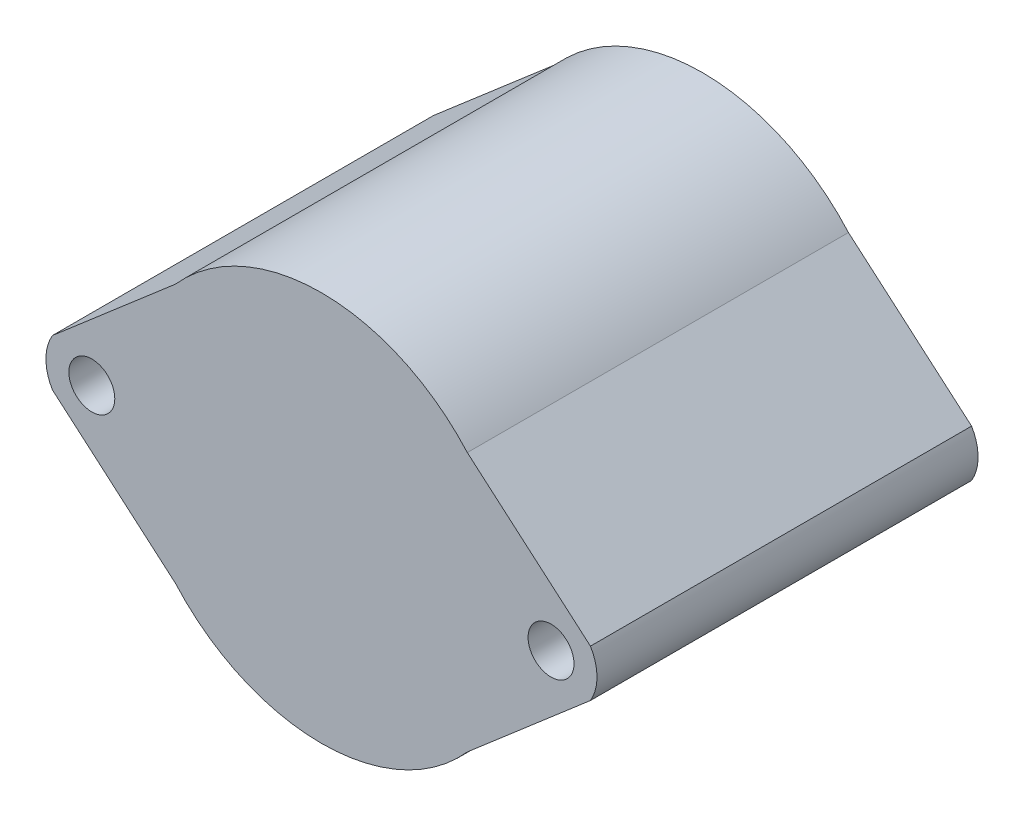
from build123d import *

# Parameters (mm, degrees)
SKETCH2_R           = 2
BOSS_EXTRUDE2_DEPTH = 33.2


with BuildPart() as part:
    # Sketch2 → Boss-Extrude2 (new body)
    with BuildSketch(Plane.XY):
        with BuildLine():
            Line((23.433804339, 2.051581771), (12.708942861, 11.290826868))
            ThreePointArc((12.708942861, 11.290826868), (0, 17), (-12.708942861, 11.290826868))
            Line((-12.708942861, 11.290826868), (-23.433804339, 2.051581771))
            ThreePointArc((-23.433804339, 2.051581771), (-24, 0), (-23.433804339, -2.051581771))
            Line((-23.433804339, -2.051581771), (-12.708942861, -11.290826868))
            ThreePointArc((-12.708942861, -11.290826868), (0, -17), (12.708942861, -11.290826868))
            Line((12.708942861, -11.290826868), (23.433804339, -2.051581771))
            ThreePointArc((23.433804339, -2.051581771), (24, 0), (23.433804339, 2.051581771))
        make_face()
        with Locations((-20, 0)):
            Circle(SKETCH2_R, mode=Mode.SUBTRACT)
        with Locations((20, 0)):
            Circle(SKETCH2_R, mode=Mode.SUBTRACT)
    extrude(amount=BOSS_EXTRUDE2_DEPTH)


solid = part.part
